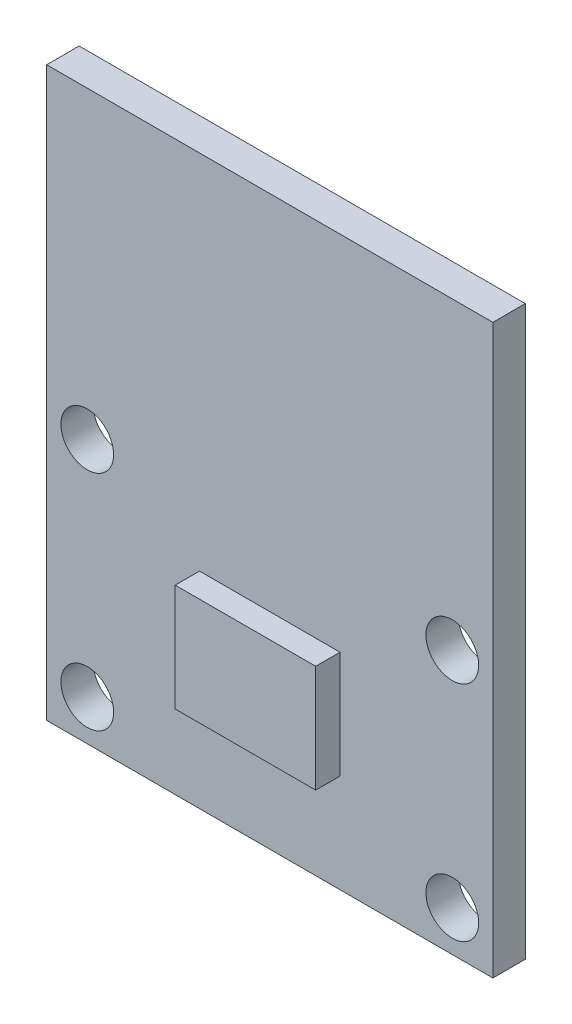
from build123d import *

# Parameters (mm, degrees)
SKETCH1_W           = 22
SKETCH1_H           = 28
SKETCH1_R           = 1.3
BOSS_EXTRUDE1_DEPTH = 1.6
SKETCH2_W           = 6.926866864
SKETCH2_H           = 5.289592926
BOSS_EXTRUDE2_DEPTH = 1.2


with BuildPart() as part:
    # Sketch1 → Boss-Extrude1 (new body)
    with BuildSketch(Plane.XY):
        Rectangle(SKETCH1_W, SKETCH1_H)
        with Locations((-9, -12)):
            Circle(SKETCH1_R, mode=Mode.SUBTRACT)
        with Locations((9, -12)):
            Circle(SKETCH1_R, mode=Mode.SUBTRACT)
        with Locations((-9, -1)):
            Circle(SKETCH1_R, mode=Mode.SUBTRACT)
        with Locations((9, -1)):
            Circle(SKETCH1_R, mode=Mode.SUBTRACT)
    extrude(amount=BOSS_EXTRUDE1_DEPTH)

    # Sketch2 → Boss-Extrude2 (add)
    with BuildSketch(Plane.XY.offset(1.6)):
        with Locations((0, -6.5)):
            Rectangle(SKETCH2_W, SKETCH2_H)
    extrude(amount=BOSS_EXTRUDE2_DEPTH)


solid = part.part
